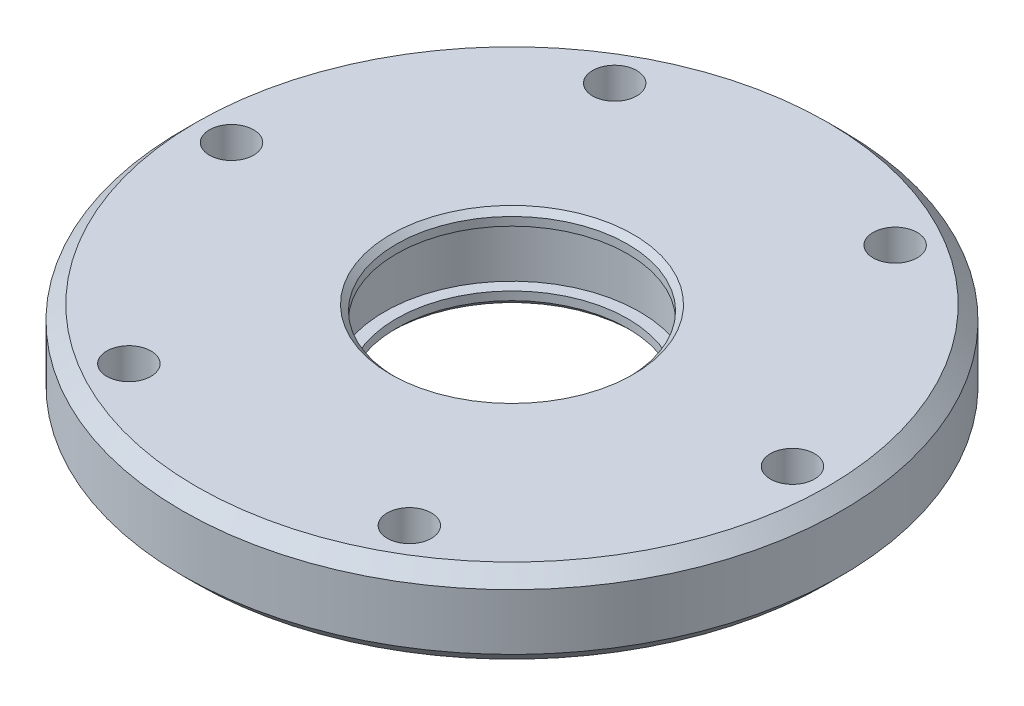
from build123d import *

# Parameters (mm, degrees)
SKETCH1_R           = 23.5
SKETCH1_R_2         = 1.575
SKETCH1_R_3         = 8.25
BOSS_EXTRUDE1_DEPTH = 3
SKETCH2_R           = 9.1
CUT_EXTRUDE1_DEPTH  = 2
SKETCH3_R           = 21.575
SKETCH3_R_2         = 18.425
BOSS_EXTRUDE2_DEPTH = 1
CHAMFER1_SIZE       = 1
CHAMFER2_SIZE       = 0.4


with BuildPart() as part:
    # Sketch1 → Boss-Extrude1 (new body, symmetric)
    with BuildSketch(Plane(origin=(0, 0, 0), x_dir=(1, 0, 0), z_dir=(0, 1, 0))):
        Circle(SKETCH1_R)
        with Locations((20, 0)):
            Circle(SKETCH1_R_2, mode=Mode.SUBTRACT)
        with Locations((10, -17.320508076)):
            Circle(SKETCH1_R_2, mode=Mode.SUBTRACT)
        with Locations((-10, -17.320508076)):
            Circle(SKETCH1_R_2, mode=Mode.SUBTRACT)
        with Locations((-20, 0)):
            Circle(SKETCH1_R_2, mode=Mode.SUBTRACT)
        with Locations((-10, 17.320508076)):
            Circle(SKETCH1_R_2, mode=Mode.SUBTRACT)
        with Locations((10, 17.320508076)):
            Circle(SKETCH1_R_2, mode=Mode.SUBTRACT)
        Circle(SKETCH1_R_3, mode=Mode.SUBTRACT)
    extrude(amount=BOSS_EXTRUDE1_DEPTH, both=True)

    # Sketch2 → Cut-Extrude1 (cut, symmetric)
    with BuildSketch(Plane(origin=(0, 0, 0), x_dir=(1, 0, 0), z_dir=(0, 1, 0))):
        Circle(SKETCH2_R)
    extrude(amount=CUT_EXTRUDE1_DEPTH, both=True, mode=Mode.SUBTRACT)

    # Sketch3 → Boss-Extrude2 (add)
    with BuildSketch(Plane(origin=(0, -3, 0), x_dir=(1, 0, 0), z_dir=(0, 1, 0))):
        Circle(SKETCH3_R)
        Circle(SKETCH3_R_2, mode=Mode.SUBTRACT)
    extrude(amount=BOSS_EXTRUDE2_DEPTH)

    # Chamfer1
    chamfer1_edges = [part.edges().sort_by_distance(p)[0] for p in [
        (-23.5, -3, 0),
        (-23.5, 3, 0),
    ]]
    chamfer(chamfer1_edges, length=CHAMFER1_SIZE)

    # Chamfer2
    chamfer2_edges = [part.edges().sort_by_distance(p)[0] for p in [
        (-8.25, -3, 0),
        (-8.25, 3, 0),
    ]]
    chamfer(chamfer2_edges, length=CHAMFER2_SIZE)


solid = part.part
